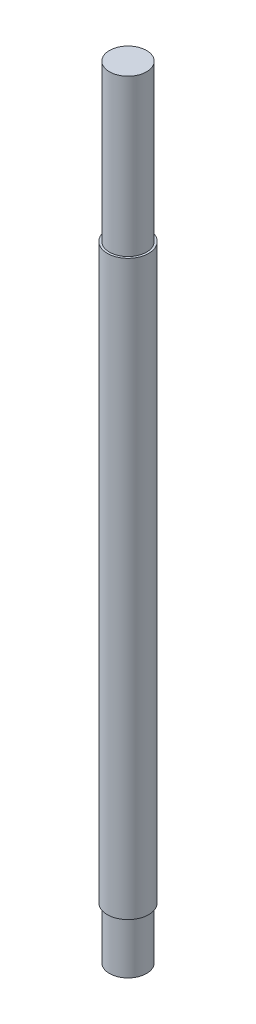
from build123d import *

# Parameters (mm, degrees)
SKETCH1_R           = 1.5875
BOSS_EXTRUDE1_DEPTH = 60
SKETCH2_R           = 1.5875
SKETCH2_R_2         = 1.4224
CUT_EXTRUDE1_DEPTH  = 4
SKETCH7_R           = 1.5875
SKETCH7_R_2         = 1.4224
CUT_EXTRUDE2_DEPTH  = 12


with BuildPart() as part:
    # Sketch1 → Boss-Extrude1 (new body)
    with BuildSketch(Plane(origin=(0, 0, 0), x_dir=(1, 0, 0), z_dir=(0, 1, 0))):
        Circle(SKETCH1_R)
    extrude(amount=BOSS_EXTRUDE1_DEPTH)

    # Sketch2 → Cut-Extrude1 (cut)
    with BuildSketch(Plane.XZ):
        Circle(SKETCH2_R)
        Circle(SKETCH2_R_2, mode=Mode.SUBTRACT)
    extrude(amount=-CUT_EXTRUDE1_DEPTH, mode=Mode.SUBTRACT)

    # Sketch7 → Cut-Extrude2 (cut)
    with BuildSketch(Plane(origin=(0, 60, 0), x_dir=(1, 0, 0), z_dir=(0, 1, 0))):
        Circle(SKETCH7_R)
        Circle(SKETCH7_R_2, mode=Mode.SUBTRACT)
    extrude(amount=-CUT_EXTRUDE2_DEPTH, mode=Mode.SUBTRACT)


solid = part.part
